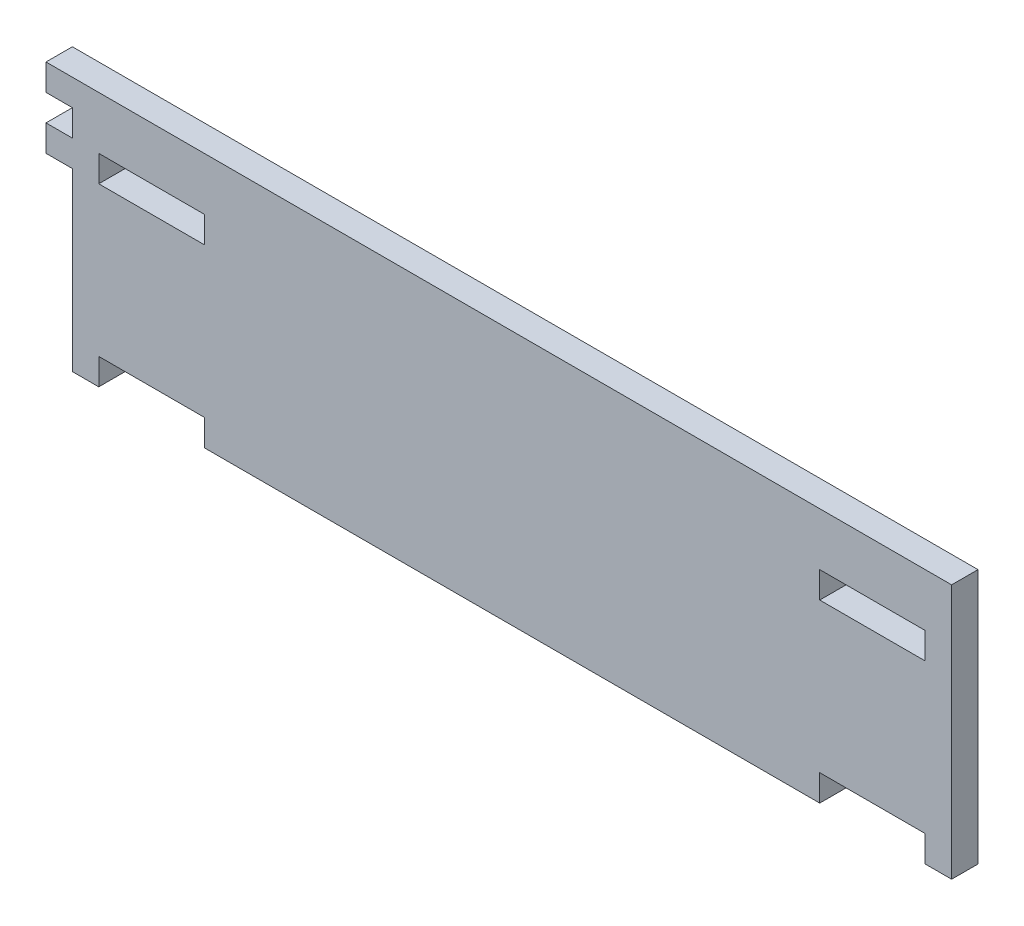
from build123d import *

# Parameters (mm, degrees)
CROQUIS1_W              = 12
CROQUIS1_H              = 3
SALIENTE_EXTRUIR1_DEPTH = 3
CROQUIS2_W              = 3
CROQUIS2_H              = 3
SALIENTE_EXTRUIR2_DEPTH = 3


with BuildPart() as part:
    # Croquis1 → Saliente-Extruir1 (new body)
    with BuildSketch(Plane.XY):
        Polygon((0, 0), (3, 0), (3, 3), (15, 3), (15, 0), (85, 0), (85, 3), (97, 3), (97, 0), (100, 0), (100, 29), (0, 29), align=None)
        with Locations((9, 21.5)):
            Rectangle(CROQUIS1_W, CROQUIS1_H, mode=Mode.SUBTRACT)
        with Locations((91, 21.5)):
            Rectangle(CROQUIS1_W, CROQUIS1_H, mode=Mode.SUBTRACT)
    extrude(amount=SALIENTE_EXTRUIR1_DEPTH)

    # Croquis2 → Saliente-Extruir2 (add)
    with BuildSketch(Plane.XY.offset(3)):
        with Locations((-1.5, 21.5)):
            Rectangle(CROQUIS2_W, CROQUIS2_H)
        with Locations((-1.5, 27.5)):
            Rectangle(CROQUIS2_W, CROQUIS2_H)
    extrude(amount=-SALIENTE_EXTRUIR2_DEPTH)


solid = part.part
